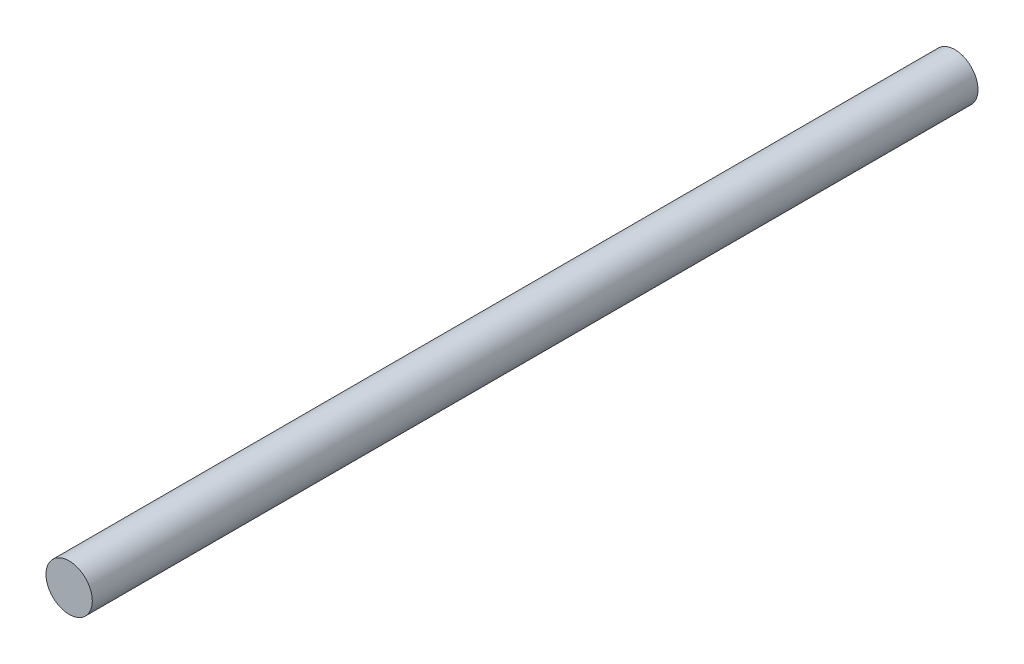
from build123d import *

# Parameters (mm, degrees)
SKETCH1_R           = 3.9878
BOSS_EXTRUDE1_DEPTH = 152.4


with BuildPart() as part:
    # Sketch1 → Boss-Extrude1 (new body)
    with BuildSketch(Plane.XY):
        Circle(SKETCH1_R)
    extrude(amount=BOSS_EXTRUDE1_DEPTH)


solid = part.part
